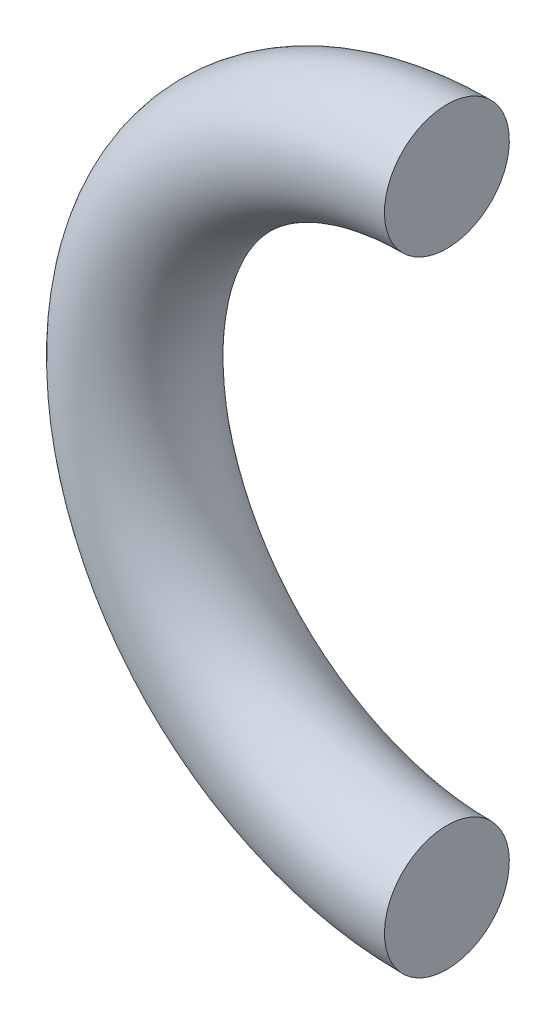
from build123d import *

# Parameters (mm, degrees)
SKETCH1_R      = 3.175
REVOLVE1_ANGLE = 180


with BuildPart() as part:
    # Sketch1 → Revolve1 (revolve)
    with BuildSketch(Plane(origin=(0, 0, 0), x_dir=(0, 0, -1), z_dir=(1, 0, 0))):
        Circle(SKETCH1_R)
    revolve(axis=Axis((0, -15.875, 0), (0, 0, 1)), revolution_arc=REVOLVE1_ANGLE)


solid = part.part
